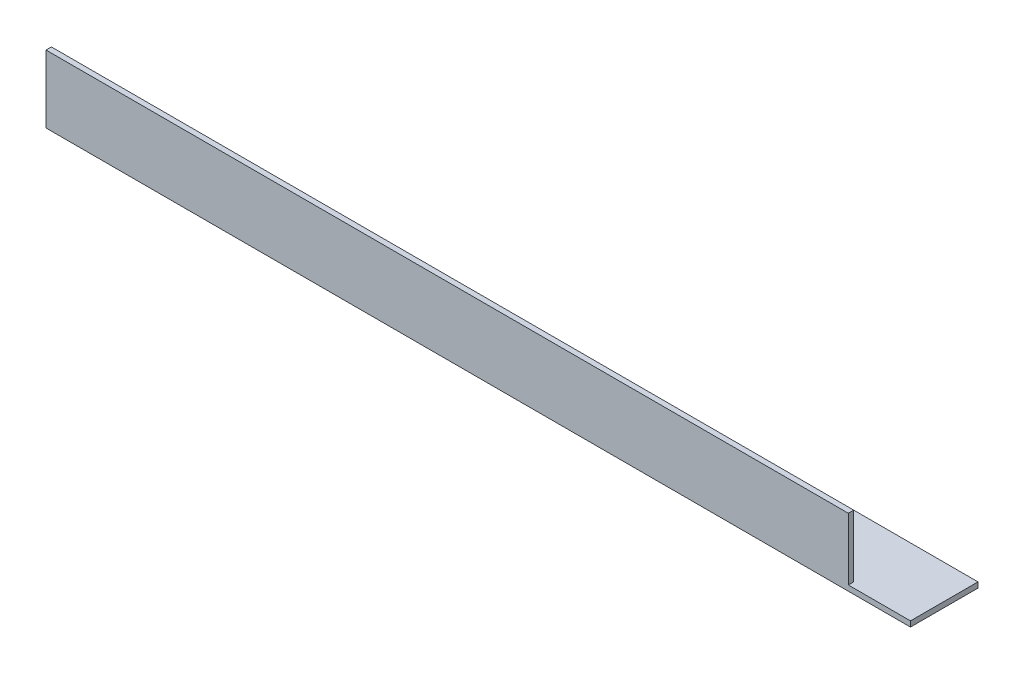
from build123d import *

# Parameters (mm, degrees)
EXTRUDE_1_DEPTH     = 320
SKETCH_3_W          = 23
SKETCH_3_H          = 23
CUT_EXTRUDE_1_DEPTH = 26


with BuildPart() as part:
    # Эскиз1 → Вытянуть-Тонкостенный1 (new body)
    with BuildSketch(Plane(origin=(0, 0, 0), x_dir=(0, 0, -1), z_dir=(1, 0, 0))):
        Polygon((0, 25), (0, 0), (25, 0), (25, 2), (2, 2), (2, 25), align=None)
    extrude(amount=EXTRUDE_1_DEPTH)

    # Эскиз3 → Вырез-Вытянуть1 (cut, through all)
    with BuildSketch(Plane.XY):
        with Locations((308.5, 13.5)):
            Rectangle(SKETCH_3_W, SKETCH_3_H)
    extrude(amount=-CUT_EXTRUDE_1_DEPTH, mode=Mode.SUBTRACT)


solid = part.part
